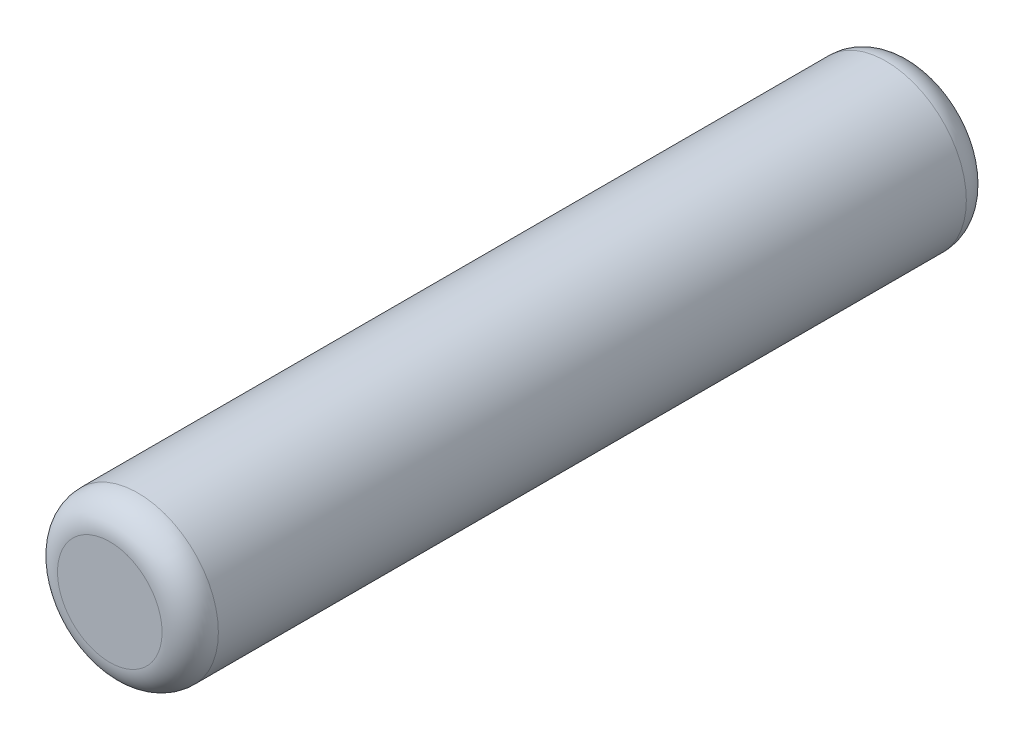
from build123d import *

# Parameters (mm, degrees)
SKETCH1_R           = 1
BOSS_EXTRUDE1_DEPTH = 5
FILLET1_R           = 0.35


with BuildPart() as part:
    # Sketch1 → Boss-Extrude1 (new body, symmetric)
    with BuildSketch(Plane.XY):
        Circle(SKETCH1_R)
    extrude(amount=BOSS_EXTRUDE1_DEPTH, both=True)

    # Fillet1
    fillet1_edges = [part.edges().sort_by_distance(p)[0] for p in [
        (-1, 0, -5),
        (-1, 0, 5),
    ]]
    fillet(fillet1_edges, radius=FILLET1_R)


solid = part.part
